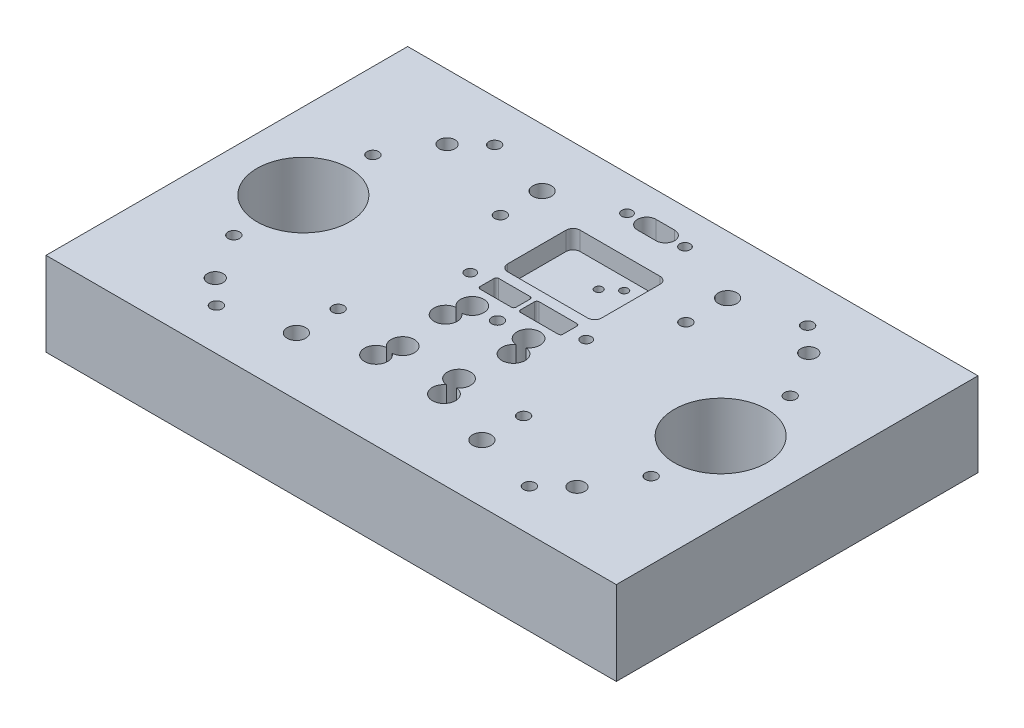
from build123d import *

# Parameters (mm, degrees)
SKETCH1_W                                           = 246
SKETCH1_H                                           = 36.2
EXTRUDE1_DEPTH                                      = 78
HOLE3_D                                             = 40
LPATTERN1_COUNT                                     = 2
LPATTERN1_PITCH                                     = 180
M6_TAPPED_HOLE1_D                                   = 5
HOLE4_D                                             = 8
M8_TAPPED_HOLE1_D                                   = 6.8
LPATTERN2_COUNT                                     = 2
LPATTERN2_PITCH                                     = 100
LPATTERN2_COUNT_DIR2                                = 2
LPATTERN2_PITCH_DIR2                                = 156
M6_TAPPED_HOLE2_D                                   = 5
M6_TAPPED_HOLE3_D                                   = 5
LPATTERN3_COUNT                                     = 2
LPATTERN3_PITCH                                     = 135
LPATTERN3_COUNT_DIR2                                = 2
LPATTERN3_PITCH_DIR2                                = 120
HOLE6_D                                             = 10
HOLE6_DEPTH                                         = 25
SKETCH30_R                                          = 2.5
CUT_EXTRUDE1_DEPTH                                  = 37.2
SKETCH31_R                                          = 5
CUT_EXTRUDE2_DEPTH                                  = 24.2
CBORE_FOR_M3_HEX_SOCKET_HEAD_CAP_SCREW1_D           = 3.4
CBORE_FOR_M3_HEX_SOCKET_HEAD_CAP_SCREW1_CBORE_D     = 6.5
CBORE_FOR_M3_HEX_SOCKET_HEAD_CAP_SCREW1_CBORE_DEPTH = 6.4
CBORE_FOR_M4_HEX_SOCKET_HEAD_CAP_SCREW1_D           = 4.5
CBORE_FOR_M4_HEX_SOCKET_HEAD_CAP_SCREW1_CBORE_D     = 8
CBORE_FOR_M4_HEX_SOCKET_HEAD_CAP_SCREW1_CBORE_DEPTH = 4.4
CUT_EXTRUDE3_DEPTH                                  = 8


with BuildPart() as part:
    # Sketch1 → Extrude1 (new body, symmetric)
    with BuildSketch(Plane.XY):
        with Locations((0, 18.1)):
            Rectangle(SKETCH1_W, SKETCH1_H)
    extrude(amount=EXTRUDE1_DEPTH, both=True)

    # Hole3 (through all)
    with Locations(Plane.XZ):
        with Locations((90, 0)):
            hole3 = Hole(HOLE3_D / 2)

    # LPattern1: Hole3 ×2
    with Locations(*[(-i * LPATTERN1_PITCH, 0, 0) for i in range(1, LPATTERN1_COUNT)]):
        add(hole3, mode=Mode.SUBTRACT)

    # M6 Tapped Hole1 (through all)
    with Locations(Plane(origin=(0, 36.2, 0), x_dir=(-1, 0, 0), z_dir=(0, 1, 0))):
        with Locations((-40, 35), (40, 35), (40, -35), (-40, -35)):
            Hole(M6_TAPPED_HOLE1_D / 2)

    # Hole4 (through all)
    with Locations(Plane(origin=(0, 36.2, 0), x_dir=(-1, 0, 0), z_dir=(0, 1, 0))):
        with Locations((-40, -53), (-40, 53), (40, 53), (40, -53)):
            Hole(HOLE4_D / 2)

    # M8 Tapped Hole1 (through all)
    with Locations(Plane(origin=(0, 36.2, 0), x_dir=(-1, 0, 0), z_dir=(0, 1, 0))):
        with Locations((78, 50)):
            m8_tapped_hole1 = Hole(M8_TAPPED_HOLE1_D / 2)

    # LPattern2: M8 Tapped Hole1 2 × 2
    with Locations(*[(j * LPATTERN2_PITCH_DIR2, 0, -i * LPATTERN2_PITCH) for i in range(LPATTERN2_COUNT) for j in range(LPATTERN2_COUNT_DIR2) if (i, j) != (0, 0)]):
        add(m8_tapped_hole1, mode=Mode.SUBTRACT)

    # M6 Tapped Hole2 (through all)
    with Locations(Plane(origin=(0, 36.2, 0), x_dir=(-1, 0, 0), z_dir=(0, 1, 0))):
        with Locations((90, 30), (90, -30), (-90, -30), (-90, 30)):
            Hole(M6_TAPPED_HOLE2_D / 2)

    # M6 Tapped Hole3 (through all)
    with Locations(Plane(origin=(0, 36.2, 0), x_dir=(-1, 0, 0), z_dir=(0, 1, 0))):
        with Locations((67.5, -60)):
            m6_tapped_hole3 = Hole(M6_TAPPED_HOLE3_D / 2)

    # LPattern3: M6 Tapped Hole3 2 × 2
    with Locations(*[(i * LPATTERN3_PITCH, 0, j * LPATTERN3_PITCH_DIR2) for i in range(LPATTERN3_COUNT) for j in range(LPATTERN3_COUNT_DIR2) if (i, j) != (0, 0)]):
        add(m6_tapped_hole3, mode=Mode.SUBTRACT)

    # Hole6
    with Locations(Plane(origin=(0, 36.2, 0), x_dir=(-1, 0, 0), z_dir=(0, 1, 0))):
        with Locations((-12.15, 35), (12.15, 35), (-12.15, 5), (12.15, 5), (14.65, 14), (-14.65, 14), (-14.65, 44), (14.65, 44)):
            Hole(HOLE6_D / 2, depth=HOLE6_DEPTH)

    # Sketch30 → Cut-Extrude1 (cut, through all)
    with BuildSketch(Plane(origin=(0, 36.2, 0), x_dir=(1, 0, 0), z_dir=(0, 1, 0))):
        with Locations((-1.269390874, -5)):
            Circle(SKETCH30_R)
        with BuildLine():
            Line((3.104640419, 59), (-4.895359581, 59))
            ThreePointArc((-4.895359581, 59), (-8.895359581, 63), (-4.895359581, 67))
            Line((-4.895359581, 67), (3.104640419, 67))
            ThreePointArc((3.104640419, 67), (7.104640419, 63), (3.104640419, 59))
        make_face()
        with BuildLine():
            Line((16.96, 11.01), (0.696577832, 11.01))
            ThreePointArc((0.696577832, 11.01), (-0.010528949, 10.717106781), (-0.303422168, 10.01))
            Line((-0.303422168, 10.01), (-0.303422168, 3.99))
            ThreePointArc((-0.303422168, 3.99), (-0.010528949, 3.282893219), (0.696577832, 2.99))
            Line((0.696577832, 2.99), (16.96, 2.99))
            ThreePointArc((16.96, 2.99), (17.667106781, 3.282893219), (17.96, 3.99))
            Line((17.96, 3.99), (17.96, 10.01))
            ThreePointArc((17.96, 10.01), (17.667106781, 10.717106781), (16.96, 11.01))
        make_face()
        with BuildLine():
            Line((-3.235359581, 11.01), (-16.735359581, 11.01))
            ThreePointArc((-16.735359581, 11.01), (-17.442466362, 10.717106781), (-17.735359581, 10.01))
            Line((-17.735359581, 10.01), (-17.735359581, 3.99))
            ThreePointArc((-17.735359581, 3.99), (-17.442466362, 3.282893219), (-16.735359581, 2.99))
            Line((-16.735359581, 2.99), (-3.235359581, 2.99))
            ThreePointArc((-3.235359581, 2.99), (-2.5282528, 3.282893219), (-2.235359581, 3.99))
            Line((-2.235359581, 3.99), (-2.235359581, 10.01))
            ThreePointArc((-2.235359581, 10.01), (-2.5282528, 10.717106781), (-3.235359581, 11.01))
        make_face()
    extrude(amount=-CUT_EXTRUDE1_DEPTH, mode=Mode.SUBTRACT)

    # Sketch31 → Cut-Extrude2 (cut)
    with BuildSketch(Plane.XZ):
        with Locations((-1.269390874, 5)):
            Circle(SKETCH31_R)
    extrude(amount=-CUT_EXTRUDE2_DEPTH, mode=Mode.SUBTRACT)

    # CBORE for M3 Hex Socket Head Cap Screw1 (through all)
    with Locations(Plane.XZ):
        with Locations((-12.195359581, -21), (12.4, -21), (0.904640419, -36.5), (6.904640419, -41.5)):
            CounterBoreHole(CBORE_FOR_M3_HEX_SOCKET_HEAD_CAP_SCREW1_D / 2, CBORE_FOR_M3_HEX_SOCKET_HEAD_CAP_SCREW1_CBORE_D / 2, CBORE_FOR_M3_HEX_SOCKET_HEAD_CAP_SCREW1_CBORE_DEPTH)

    # CBORE for M4 Hex Socket Head Cap Screw1 (through all)
    with Locations(Plane.XZ):
        with Locations((-25, -7), (25, -7), (-13.395359581, -63), (11.604640419, -63)):
            CounterBoreHole(CBORE_FOR_M4_HEX_SOCKET_HEAD_CAP_SCREW1_D / 2, CBORE_FOR_M4_HEX_SOCKET_HEAD_CAP_SCREW1_CBORE_D / 2, CBORE_FOR_M4_HEX_SOCKET_HEAD_CAP_SCREW1_CBORE_DEPTH)

    # Sketch36 → Cut-Extrude3 (cut)
    with BuildSketch(Plane(origin=(0, 36.2, 0), x_dir=(1, 0, 0), z_dir=(0, 1, 0))):
        with BuildLine():
            Line((17.25, 46.6), (-17.25, 46.6))
            ThreePointArc((-17.25, 46.6), (-19.371320344, 45.721320344), (-20.25, 43.6))
            Line((-20.25, 43.6), (-20.25, 18.4))
            ThreePointArc((-20.25, 18.4), (-19.371320344, 16.278679656), (-17.25, 15.4))
            Line((-17.25, 15.4), (17.25, 15.4))
            ThreePointArc((17.25, 15.4), (19.371320344, 16.278679656), (20.25, 18.4))
            Line((20.25, 18.4), (20.25, 43.6))
            ThreePointArc((20.25, 43.6), (19.371320344, 45.721320344), (17.25, 46.6))
        make_face()
    extrude(amount=-CUT_EXTRUDE3_DEPTH, mode=Mode.SUBTRACT)


solid = part.part
